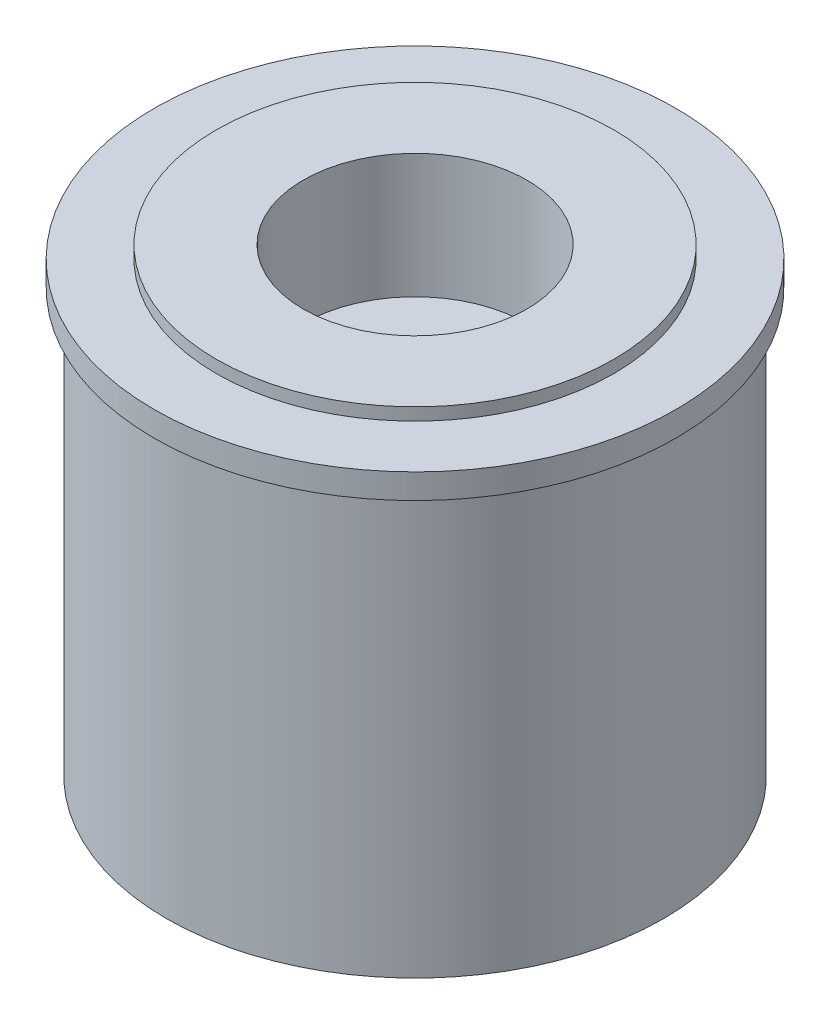
from build123d import *

# Parameters (mm, degrees)
SKETCH1_R          = 10
SKETCH1_R_2        = 8
EXTRUDE1_DEPTH     = 17
EXTRUDE3_START     = -9
SKETCH2_R          = 8
EXTRUDE3_DEPTH     = 10.5
SKETCH3_R          = 10.5
EXTRUDE4_DEPTH     = 1
SKETCH4_R          = 4.5
CUT_EXTRUDE1_DEPTH = 5
SKETCH6_R          = 2
CUT_EXTRUDE4_DEPTH = 5
CIRPATTERN1_COUNT  = 4
SKETCH7_W          = 0.4
SKETCH7_H          = 0.4
CUT_EXTRUDE5_DEPTH = 14.5
CIRPATTERN2_COUNT  = 4


with BuildPart() as part:
    # Sketch1 → Extrude1 (new body)
    with BuildSketch(Plane(origin=(0, 0, 0), x_dir=(1, 0, 0), z_dir=(0, 1, 0))):
        Circle(SKETCH1_R)
        Circle(SKETCH1_R_2, mode=Mode.SUBTRACT)
    extrude(amount=EXTRUDE1_DEPTH)

    # Sketch2 → Extrude3 (add)
    with BuildSketch(Plane(origin=(0, 17, 0), x_dir=(-1, 0, 0), z_dir=(0, 1, 0)).offset(EXTRUDE3_START)):
        Circle(SKETCH2_R)
    extrude(amount=EXTRUDE3_DEPTH)

    # Sketch3 → Extrude4 (add)
    with BuildSketch(Plane(origin=(0, 17, 0), x_dir=(-1, 0, 0), z_dir=(0, 1, 0))):
        Circle(SKETCH3_R)
    extrude(amount=EXTRUDE4_DEPTH)

    # Sketch4 → Cut-Extrude1 (cut)
    with BuildSketch(Plane(origin=(0, 18.5, 0), x_dir=(-1, 0, 0), z_dir=(0, 1, 0))):
        Circle(SKETCH4_R)
    extrude(amount=-CUT_EXTRUDE1_DEPTH, mode=Mode.SUBTRACT)

    # Sketch6 → Cut-Extrude4 (cut)
    with BuildSketch(Plane.XZ.offset(-8)):
        with Locations((6, 0)):
            Circle(SKETCH6_R)
    cut_extrude4 = extrude(amount=-CUT_EXTRUDE4_DEPTH, mode=Mode.SUBTRACT)

    # CirPattern1: Cut-Extrude4 ×4 about axis
    cirpattern1_axis = Axis((0, 0, 0), (0, 1, 0))
    for i in range(1, CIRPATTERN1_COUNT):
        add(cut_extrude4.rotate(cirpattern1_axis, i * 360 / CIRPATTERN1_COUNT), mode=Mode.SUBTRACT)

    # Sketch7 → Cut-Extrude5 (cut, through all)
    with BuildSketch(Plane(origin=(0, 13.5, 0), x_dir=(-1, 0, 0), z_dir=(0, 1, 0))):
        with Locations((-4.259587971, 0)):
            Rectangle(SKETCH7_W, SKETCH7_H)
    cut_extrude5 = extrude(amount=-CUT_EXTRUDE5_DEPTH, mode=Mode.SUBTRACT)

    # CirPattern2: Cut-Extrude5 ×4 about axis
    cirpattern2_axis = Axis((0, 0, 0), (0, 1, 0))
    for i in range(1, CIRPATTERN2_COUNT):
        add(cut_extrude5.rotate(cirpattern2_axis, i * 360 / CIRPATTERN2_COUNT), mode=Mode.SUBTRACT)


solid = part.part
